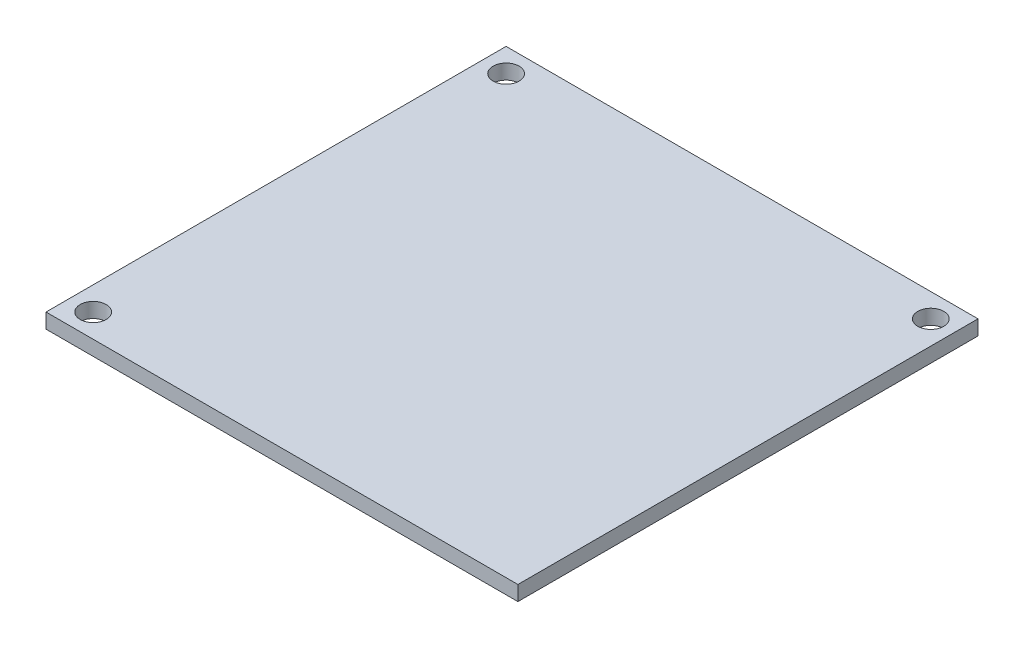
from build123d import *

# Parameters (mm, degrees)
SKETCH2_W           = 50.8
SKETCH2_H           = 49.53
BOSS_EXTRUDE1_DEPTH = 1.6
SKETCH3_R           = 1.4
CUT_EXTRUDE1_DEPTH  = 1.6


with BuildPart() as part:
    # Sketch2 → Boss-Extrude1 (new body)
    with BuildSketch(Plane(origin=(0, 0, 0), x_dir=(1, 0, 0), z_dir=(0, 1, 0))):
        Rectangle(SKETCH2_W, SKETCH2_H)
    extrude(amount=BOSS_EXTRUDE1_DEPTH)

    # Sketch3 → Cut-Extrude1 (cut)
    with BuildSketch(Plane(origin=(0, 1.6, 0), x_dir=(1, 0, 0), z_dir=(0, 1, 0))):
        with Locations((-22.86, 22.225)):
            Circle(SKETCH3_R)
        with Locations((22.86, 22.225)):
            Circle(SKETCH3_R)
        with Locations((-22.86, -22.225)):
            Circle(SKETCH3_R)
    extrude(amount=-CUT_EXTRUDE1_DEPTH, mode=Mode.SUBTRACT)


solid = part.part
